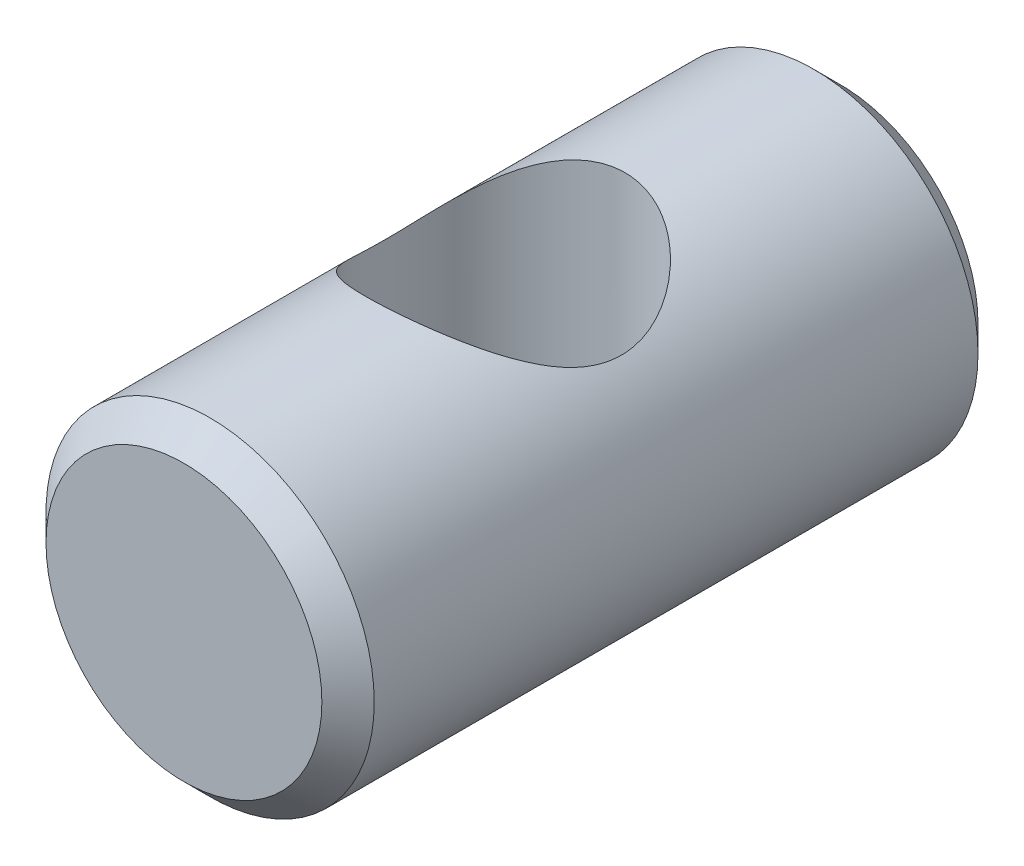
from build123d import *

# Parameters (mm, degrees)
SKETCH2_R               = 4.765
BOSS_EXTRUDE1_DEPTH     = 9.525
CHAMFER1_SIZE           = 0.76
SKETCH3_R               = 3.43
CUT_EXTRUDE1_DEPTH      = 5.765
CUT_EXTRUDE1_DEPTH_BACK = 5.765


with BuildPart() as part:
    # Sketch2 → Boss-Extrude1 (new body, symmetric)
    with BuildSketch(Plane.XY):
        Circle(SKETCH2_R)
    extrude(amount=BOSS_EXTRUDE1_DEPTH, both=True)

    # Chamfer1
    chamfer1_edges = [part.edges().sort_by_distance(p)[0] for p in [
        (-4.765, 0, -9.525),
        (-4.765, 0, 9.525),
    ]]
    chamfer(chamfer1_edges, length=CHAMFER1_SIZE)

    # Sketch3 → Cut-Extrude1 (cut, two sides)
    with BuildSketch(Plane(origin=(0, 0, 0), x_dir=(1, 0, 0), z_dir=(0, 1, 0))) as cut_extrude1_sk:
        with Locations((-0.25, 0)):
            Circle(SKETCH3_R)
    extrude(amount=CUT_EXTRUDE1_DEPTH, mode=Mode.SUBTRACT)
    extrude(cut_extrude1_sk.sketch, amount=-CUT_EXTRUDE1_DEPTH_BACK, mode=Mode.SUBTRACT)


solid = part.part
